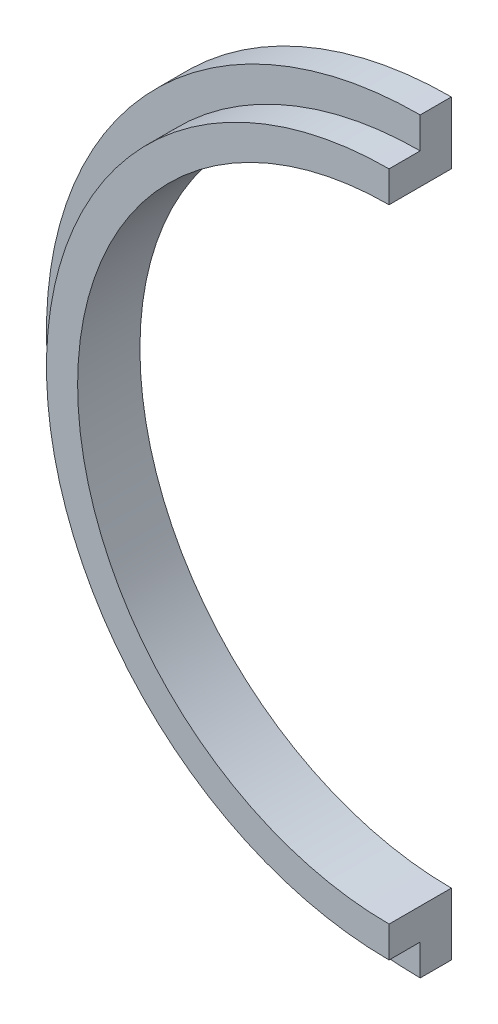
from build123d import *

# Parameters (mm, degrees)
SKETCH1_R           = 180
SKETCH1_R_2         = 150
BOSS_EXTRUDE1_DEPTH = 15
SKETCH2_R           = 165
SKETCH2_R_2         = 150
BOSS_EXTRUDE2_DEPTH = 15
CUT_EXTRUDE1_REACH  = 32
SKETCH3_W           = 245
SKETCH3_H           = 360


with BuildPart() as part:
    # Sketch1 → Boss-Extrude1 (new body)
    with BuildSketch(Plane.XY):
        Circle(SKETCH1_R)
        Circle(SKETCH1_R_2, mode=Mode.SUBTRACT)
    extrude(amount=BOSS_EXTRUDE1_DEPTH)

    # Sketch2 → Boss-Extrude2 (add)
    with BuildSketch(Plane.XY.offset(15)):
        Circle(SKETCH2_R)
        Circle(SKETCH2_R_2, mode=Mode.SUBTRACT)
    extrude(amount=BOSS_EXTRUDE2_DEPTH)

    # Sketch3 → Cut-Extrude1 (cut, up to next)
    with BuildSketch(Plane.XY, mode=Mode.PRIVATE) as cut_extrude1_sk1:
        with Locations((122.5, 0)):
            Rectangle(SKETCH3_W, SKETCH3_H)
    cut_extrude1_tool1 = extrude(cut_extrude1_sk1.sketch, amount=CUT_EXTRUDE1_REACH, mode=Mode.PRIVATE) & part.part
    add(cut_extrude1_tool1.solids().sort_by_distance((122.5, 0, 0))[0], mode=Mode.SUBTRACT)


solid = part.part
